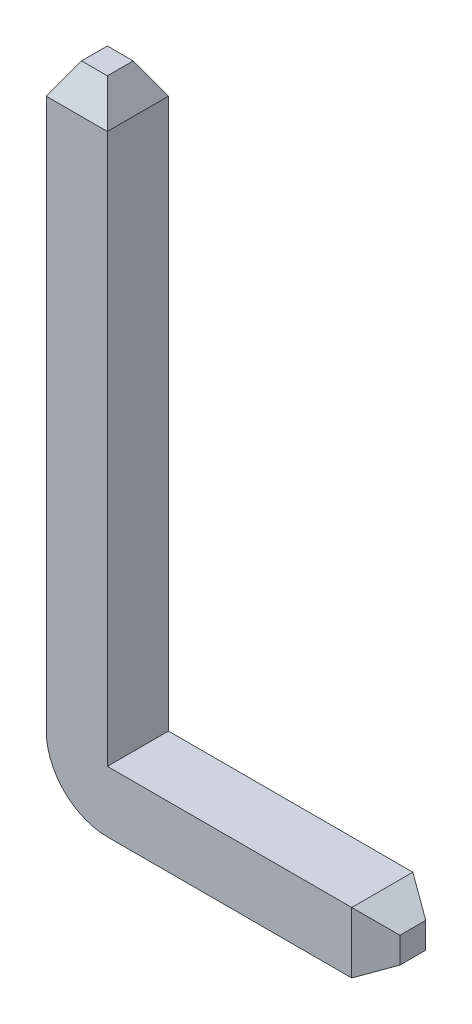
from build123d import *

# Parameters (mm, degrees)
SKETCH2_W             = 0.4
SKETCH2_H             = 0.4
CHAMFER1_SIZE         = 0.2
CHAMFER1_SIZE2        = 0.115470054
CHAMFER1_PART_2_SIZE  = 0.2
CHAMFER1_PART_2_SIZE2 = 0.115470054
CHAMFER1_PART_3_SIZE  = 0.2
CHAMFER1_PART_3_SIZE2 = 0.115470054
CHAMFER1_PART_4_SIZE  = 0.2
CHAMFER1_PART_4_SIZE2 = 0.115470054
CHAMFER2_SIZE         = 0.2
CHAMFER2_SIZE2        = 0.115470054
CHAMFER2_PART_2_SIZE  = 0.2
CHAMFER2_PART_2_SIZE2 = 0.115470054
CHAMFER2_PART_3_SIZE  = 0.2
CHAMFER2_PART_3_SIZE2 = 0.115470054
CHAMFER2_PART_4_SIZE  = 0.2
CHAMFER2_PART_4_SIZE2 = 0.115470054


with BuildPart() as part:
    # Sweep1: sweep along a path in Sketch1
    with BuildLine(Plane.XY) as sweep1_path:
        Line((0, 4), (0, 0.2))
        ThreePointArc((0, 0.2), (0.058578644, 0.058578644), (0.2, 0))
        Line((0.2, 0), (2, 0))
    # Sketch2 → Sweep1 (sweep)
    with BuildSketch(Plane(origin=(0, 4, 0), x_dir=(1, 0, 0), z_dir=(0, 1, 0))):
        Rectangle(SKETCH2_W, SKETCH2_H)
    sweep(path=sweep1_path.line)

    # Chamfer1
    chamfer1_edges = [part.edges().sort_by_distance(p)[0] for p in [
        (0, 4, 0.2),
    ]]
    chamfer1_side = [part.faces().sort_by_distance(p)[0] for p in [
        (-0.152586922, 2.1, 0.2),
    ]]
    chamfer(chamfer1_edges, length=CHAMFER1_SIZE, length2=CHAMFER1_SIZE2, reference=chamfer1_side[0])

    # Chamfer1 part 2
    chamfer1_part_2_edges = [part.edges().sort_by_distance(p)[0] for p in [
        (-0.2, 4, 0),
    ]]
    chamfer1_part_2_side = [part.faces().sort_by_distance(p)[0] for p in [
        (-0.2, 2.1, 0),
    ]]
    chamfer(chamfer1_part_2_edges, length=CHAMFER1_PART_2_SIZE, length2=CHAMFER1_PART_2_SIZE2, reference=chamfer1_part_2_side[0])

    # Chamfer1 part 3
    chamfer1_part_3_edges = [part.edges().sort_by_distance(p)[0] for p in [
        (0, 4, -0.2),
    ]]
    chamfer1_part_3_side = [part.faces().sort_by_distance(p)[0] for p in [
        (0.152586922, 2.1, -0.2),
    ]]
    chamfer(chamfer1_part_3_edges, length=CHAMFER1_PART_3_SIZE, length2=CHAMFER1_PART_3_SIZE2, reference=chamfer1_part_3_side[0])

    # Chamfer1 part 4
    chamfer1_part_4_edges = [part.edges().sort_by_distance(p)[0] for p in [
        (0.2, 4, 0),
    ]]
    chamfer1_part_4_side = [part.faces().sort_by_distance(p)[0] for p in [
        (0.2, 2.1, 0),
    ]]
    chamfer(chamfer1_part_4_edges, length=CHAMFER1_PART_4_SIZE, length2=CHAMFER1_PART_4_SIZE2, reference=chamfer1_part_4_side[0])

    # Chamfer2
    chamfer2_edges = [part.edges().sort_by_distance(p)[0] for p in [
        (2, 0.2, 0),
    ]]
    chamfer2_side = [part.faces().sort_by_distance(p)[0] for p in [
        (1.1, 0.2, 0),
    ]]
    chamfer(chamfer2_edges, length=CHAMFER2_SIZE, length2=CHAMFER2_SIZE2, reference=chamfer2_side[0])

    # Chamfer2 part 2
    chamfer2_part_2_edges = [part.edges().sort_by_distance(p)[0] for p in [
        (2, 0, -0.2),
    ]]
    chamfer2_part_2_side = [part.faces().sort_by_distance(p)[0] for p in [
        (0.154349151, 2, -0.2),
    ]]
    chamfer(chamfer2_part_2_edges, length=CHAMFER2_PART_2_SIZE, length2=CHAMFER2_PART_2_SIZE2, reference=chamfer2_part_2_side[0])

    # Chamfer2 part 3
    chamfer2_part_3_edges = [part.edges().sort_by_distance(p)[0] for p in [
        (2, -0.2, 0),
    ]]
    chamfer2_part_3_side = [part.faces().sort_by_distance(p)[0] for p in [
        (1.1, -0.2, 0),
    ]]
    chamfer(chamfer2_part_3_edges, length=CHAMFER2_PART_3_SIZE, length2=CHAMFER2_PART_3_SIZE2, reference=chamfer2_part_3_side[0])

    # Chamfer2 part 4
    chamfer2_part_4_edges = [part.edges().sort_by_distance(p)[0] for p in [
        (2, 0, 0.2),
    ]]
    chamfer2_part_4_side = [part.faces().sort_by_distance(p)[0] for p in [
        (-0.154349151, 2, 0.2),
    ]]
    chamfer(chamfer2_part_4_edges, length=CHAMFER2_PART_4_SIZE, length2=CHAMFER2_PART_4_SIZE2, reference=chamfer2_part_4_side[0])


solid = part.part
